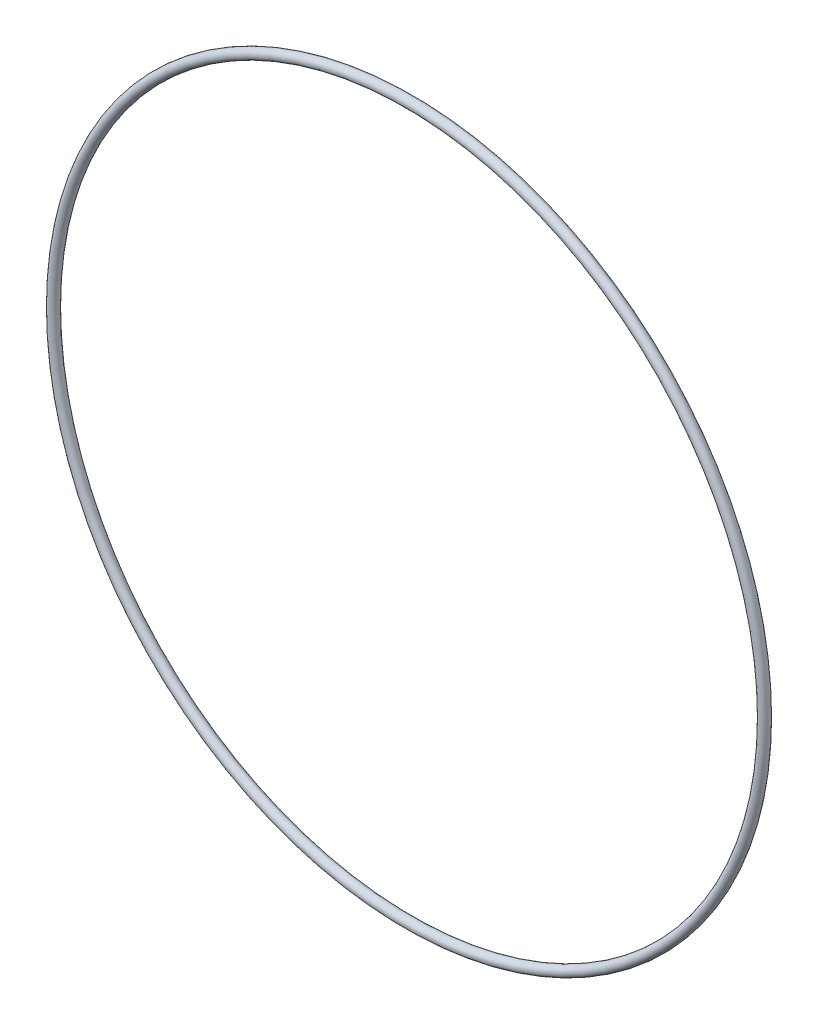
from build123d import *

# Parameters (mm, degrees)
SKETCH1_R = 1.7653


with BuildPart() as part:
    # Sketch1 → Revolve1 (revolve)
    with BuildSketch(Plane(origin=(0, 0, 0), x_dir=(0, -1, 0), z_dir=(1, 0, 0))):
        with Locations((125.3871, 0)):
            Circle(SKETCH1_R)
    revolve(axis=Axis((0, 0, 1.7653), (0, 0, -1)))


solid = part.part
